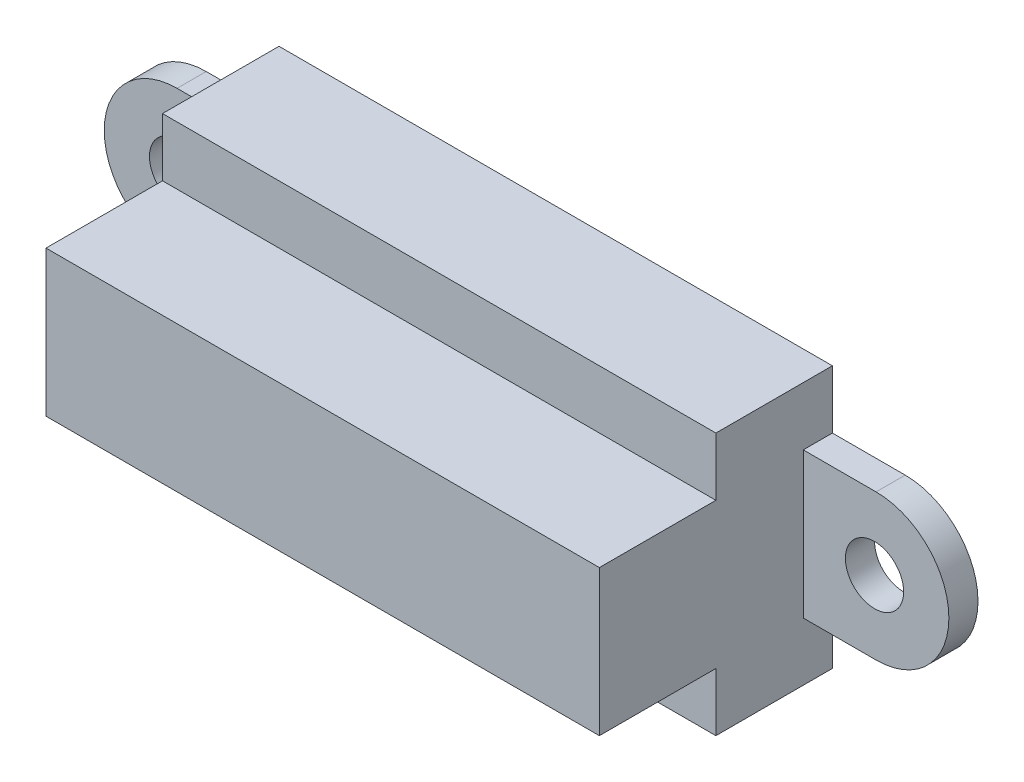
from build123d import *

# Parameters (mm, degrees)
SKETCH1_W           = 30.1625
SKETCH1_H           = 14.2875
BOSS_EXTRUDE1_DEPTH = 6.35
SKETCH2_W           = 30.1625
SKETCH2_H           = 7.9375
BOSS_EXTRUDE2_DEPTH = 6.35
BOSS_EXTRUDE3_DEPTH = 1.5875
SKETCH4_R           = 1.5875
CUT_EXTRUDE1_DEPTH  = 1.5875


with BuildPart() as part:
    # Sketch1 → Boss-Extrude1 (new body)
    with BuildSketch(Plane.XY):
        Rectangle(SKETCH1_W, SKETCH1_H)
    extrude(amount=BOSS_EXTRUDE1_DEPTH)

    # Sketch2 → Boss-Extrude2 (add)
    with BuildSketch(Plane.XY.offset(6.35)):
        Rectangle(SKETCH2_W, SKETCH2_H)
    extrude(amount=BOSS_EXTRUDE2_DEPTH)

    # Sketch3 → Boss-Extrude3 (add)
    with BuildSketch(Plane(origin=(0, 0, 0), x_dir=(-1, 0, 0), z_dir=(0, 0, -1))):
        with BuildLine():
            ThreePointArc((-15.08125, 0), (-16.243669962, 2.806330038), (-19.05, 3.96875))
            Line((-19.05, 3.96875), (-19.05, -3.96875))
            ThreePointArc((-19.05, -3.96875), (-16.243669962, -2.806330038), (-15.08125, 0))
        make_face()
        with BuildLine():
            Line((-19.05, -3.96875), (-19.05, 3.96875))
            ThreePointArc((-19.05, 3.96875), (-23.01875, 0), (-19.05, -3.96875))
        make_face()
        with BuildLine():
            Line((-15.08125, 3.96875), (-19.05, 3.96875))
            ThreePointArc((-19.05, 3.96875), (-16.243669962, 2.806330038), (-15.08125, 0))
            Line((-15.08125, 0), (-15.08125, 3.96875))
        make_face()
        with BuildLine():
            ThreePointArc((-15.08125, 0), (-16.243669962, -2.806330038), (-19.05, -3.96875))
            Line((-19.05, -3.96875), (-15.08125, -3.96875))
            Line((-15.08125, -3.96875), (-15.08125, 0))
        make_face()
    boss_extrude3 = extrude(amount=-BOSS_EXTRUDE3_DEPTH)

    # Sketch4 → Cut-Extrude1 (cut)
    with BuildSketch(Plane.XY.offset(1.5875)):
        with Locations((18.966101938, 0)):
            Circle(SKETCH4_R)
    cut_extrude1 = extrude(amount=-CUT_EXTRUDE1_DEPTH, mode=Mode.SUBTRACT)

    # Mirror1: Boss-Extrude3, Cut-Extrude1 across plane
    add(boss_extrude3.mirror(Plane(origin=(0, 0, 0), x_dir=(0, 0, 1), z_dir=(1, 0, 0))))
    add(cut_extrude1.mirror(Plane(origin=(0, 0, 0), x_dir=(0, 0, 1), z_dir=(1, 0, 0))), mode=Mode.SUBTRACT)


solid = part.part
